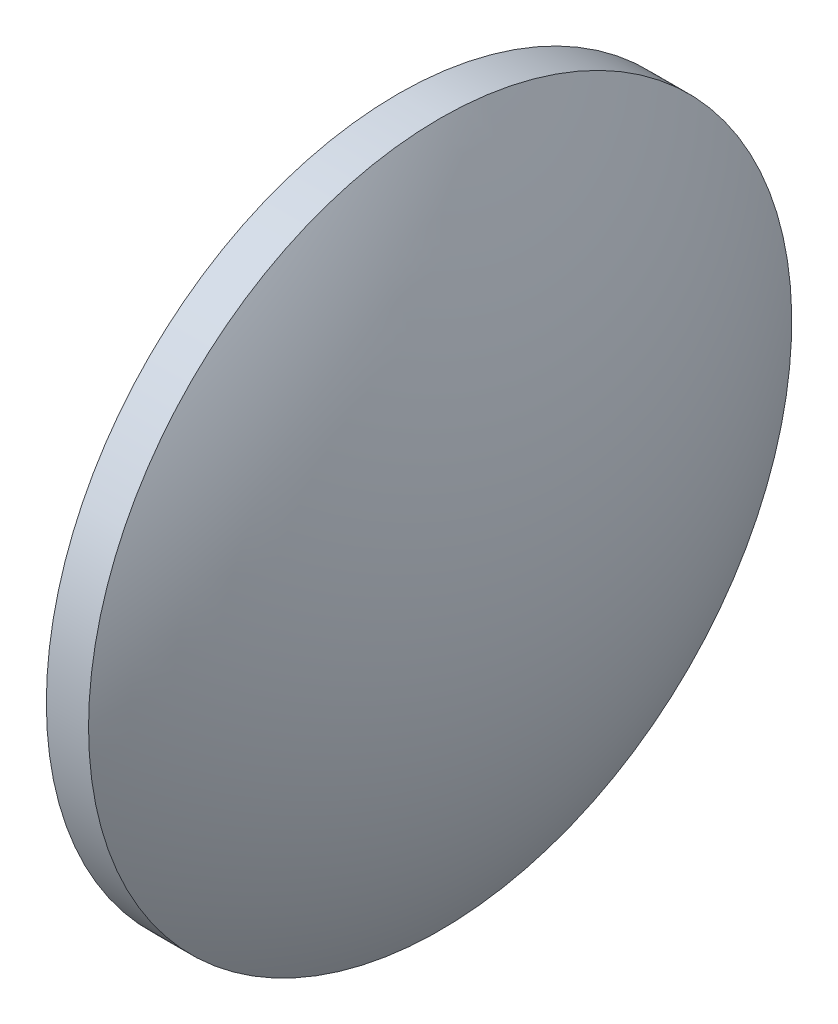
from build123d import *

# Parameters (mm, degrees)
SKETCH_1_ONE_SIDE_W = 3
SKETCH_1_ONE_SIDE_H = 25


with BuildPart() as part:
    # 草图1 one side → 旋转1 (revolve)
    with BuildSketch(Plane.XY):
        with Locations((170.193294832, 108.201009888)):
            Rectangle(SKETCH_1_ONE_SIDE_W, SKETCH_1_ONE_SIDE_H)
        with BuildLine():
            Line((161.768294832, 95.701009888), (168.693294832, 95.701009888))
            Line((168.693294832, 95.701009888), (168.693294832, 120.701009888))
            ThreePointArc((168.693294832, 120.701009888), (163.53153804, 108.67170402), (161.768294832, 95.701009888))
        make_face()
        with BuildLine():
            Line((171.693294832, 95.701009888), (178.618294832, 95.701009888))
            ThreePointArc((178.618294832, 95.701009888), (176.855051624, 108.67170402), (171.693294832, 120.701009888))
            Line((171.693294832, 120.701009888), (171.693294832, 95.701009888))
        make_face()
    revolve(axis=Axis((157.940955212, 95.701009888, 0), (1, 0, 0)))


solid = part.part
